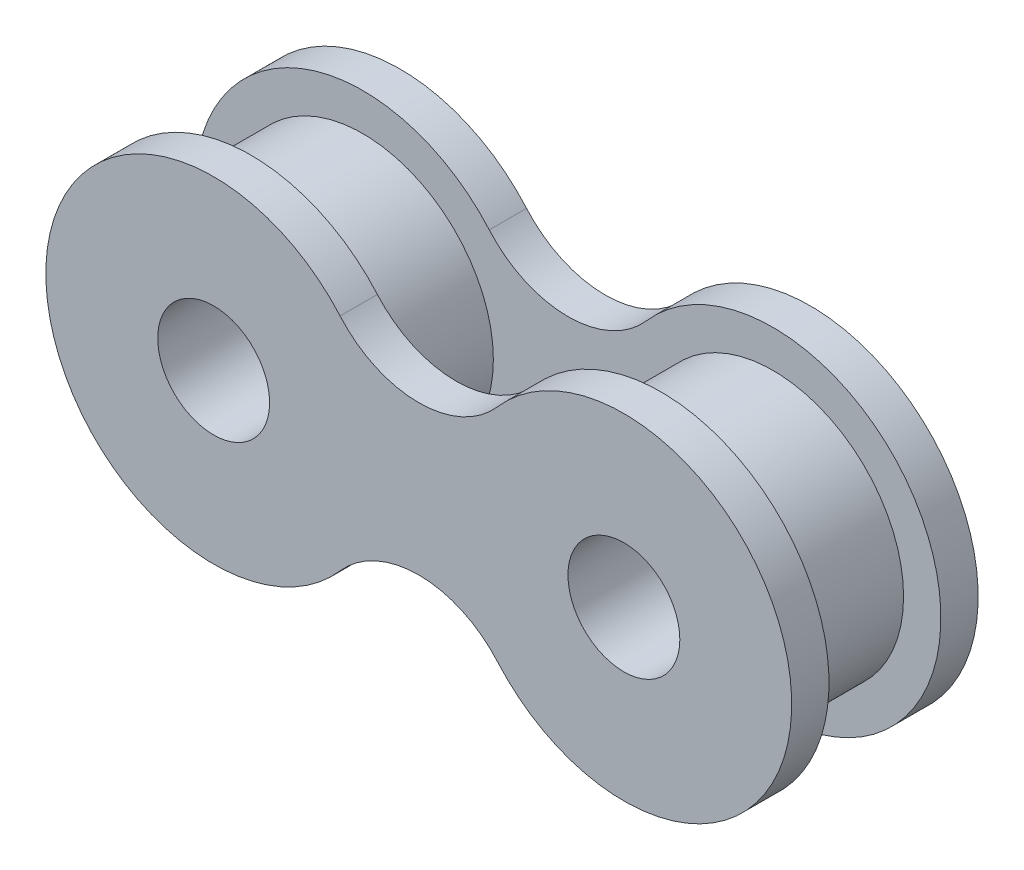
from build123d import *

# Parameters (mm, degrees)
CROQUIS1_R              = 1.5
SALIENTE_EXTRUIR1_DEPTH = 1
CROQUIS2_R              = 3.5
CROQUIS2_R_2            = 1.5
SALIENTE_EXTRUIR2_DEPTH = 3
CROQUIS3_R              = 1.5
SALIENTE_EXTRUIR3_DEPTH = 1


with BuildPart() as part:
    # Croquis1 → Saliente-Extruir1 (new body)
    with BuildSketch(Plane.XY):
        with BuildLine():
            ThreePointArc((2.109589041, -2.95890411), (10, 0), (2.109589041, 2.95890411))
            ThreePointArc((2.109589041, 2.95890411), (0, 2), (-2.109589041, 2.95890411))
            ThreePointArc((-2.109589041, 2.95890411), (-10, 0), (-2.109589041, -2.95890411))
            ThreePointArc((-2.109589041, -2.95890411), (0, -2), (2.109589041, -2.95890411))
        make_face()
        with Locations((-5.5, 0)):
            Circle(CROQUIS1_R, mode=Mode.SUBTRACT)
        with Locations((5.5, 0)):
            Circle(CROQUIS1_R, mode=Mode.SUBTRACT)
    extrude(amount=SALIENTE_EXTRUIR1_DEPTH)

    # Croquis2 → Saliente-Extruir2 (add)
    with BuildSketch(Plane.XY.offset(1)):
        with Locations((-5.5, 0)):
            Circle(CROQUIS2_R)
        with Locations((-5.5, 0)):
            Circle(CROQUIS2_R_2, mode=Mode.SUBTRACT)
        with Locations((5.5, 0)):
            Circle(CROQUIS2_R)
        with Locations((5.5, 0)):
            Circle(CROQUIS2_R_2, mode=Mode.SUBTRACT)
    extrude(amount=SALIENTE_EXTRUIR2_DEPTH)

    # Croquis3 → Saliente-Extruir3 (add)
    with BuildSketch(Plane.XY.offset(4)):
        with BuildLine():
            ThreePointArc((-2.109589041, 2.95890411), (0, 2), (2.109589041, 2.95890411))
            ThreePointArc((2.109589041, 2.95890411), (10, 0), (2.109589041, -2.95890411))
            ThreePointArc((2.109589041, -2.95890411), (0, -2), (-2.109589041, -2.95890411))
            ThreePointArc((-2.109589041, -2.95890411), (-10, 0), (-2.109589041, 2.95890411))
        make_face()
        with Locations((-5.5, 0)):
            Circle(CROQUIS3_R, mode=Mode.SUBTRACT)
        with Locations((5.5, 0)):
            Circle(CROQUIS3_R, mode=Mode.SUBTRACT)
    extrude(amount=SALIENTE_EXTRUIR3_DEPTH)


solid = part.part
